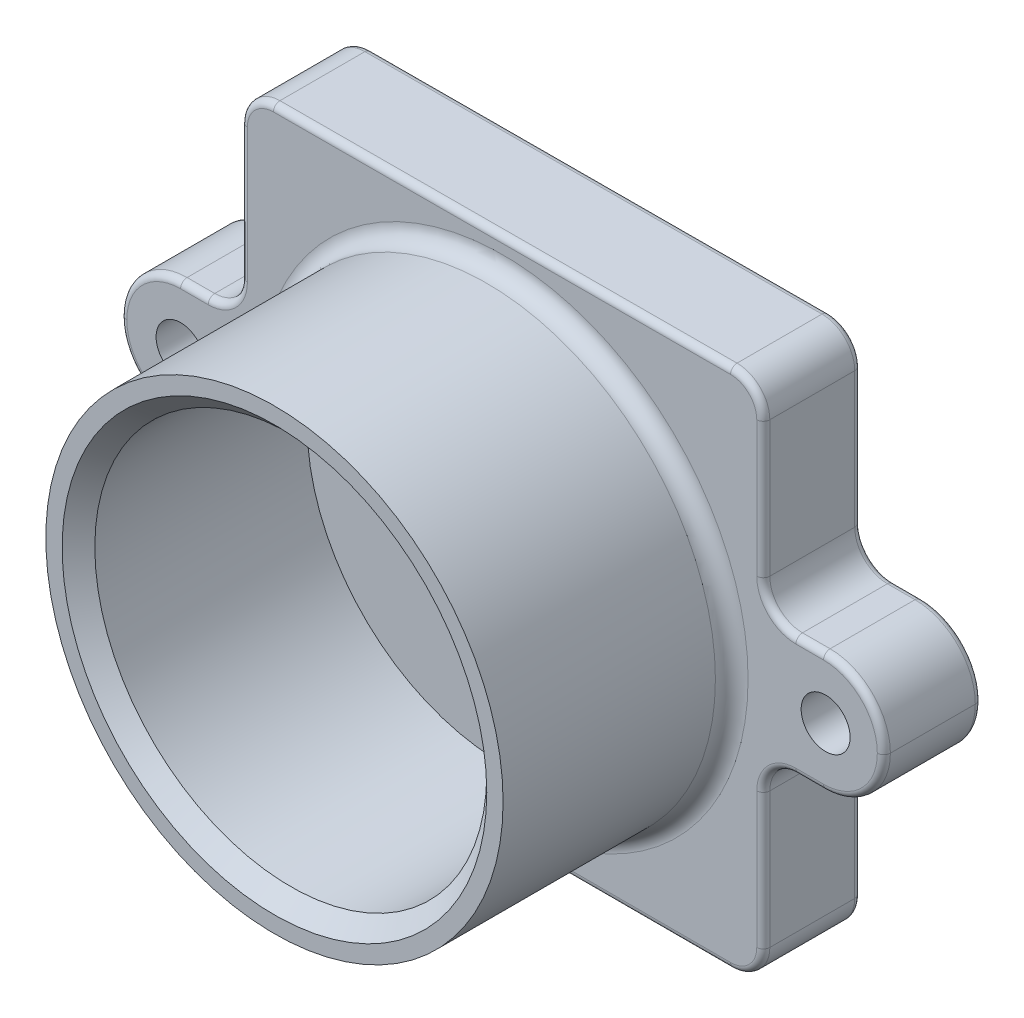
from build123d import *

# Parameters (mm, degrees)
BOSS_EXTRUDE1_DEPTH = 254
SKETCH2_OUTSIDE_W   = 748.341
SKETCH2_OUTSIDE_H   = 560.841
SKETCH2_OUTSIDE_R   = 177.8
CUT_EXTRUDE1_DEPTH  = 177.8
SKETCH3_R           = 152.4
CUT_EXTRUDE2_DEPTH  = 177.8
SKETCH4_R           = 19.05
CUT_EXTRUDE3_DEPTH  = 77.2
FILLET1_R           = 25.4
FILLET2_R           = 12.7
CHAMFER1_SIZE       = 12.7
FILLET3_R           = 5.08


with BuildPart() as part:
    # Sketch1 → Boss-Extrude1 (new body)
    with BuildSketch(Plane.XY):
        with BuildLine():
            Line((-203.92210878, 202.478230518), (202.328853722, 203.603457768))
            Line((202.328853722, 203.603457768), (202.328853722, 47.353145268))
            Line((202.328853722, 47.353145268), (249.203997472, 47.353145268))
            ThreePointArc((249.203997472, 47.353145268), (282.349757422, 33.623736467), (296.079166223, 0.477976517))
            ThreePointArc((296.079166223, 0.477976517), (282.349757422, -32.667783432), (249.203997472, -46.397192233))
            Line((249.203997472, -46.397192233), (202.328853722, -46.397192233))
            Line((202.328853722, -46.397192233), (202.328853722, -202.647504734))
            Line((202.328853722, -202.647504734), (-203.92210878, -202.647504734))
            Line((-203.92210878, -202.647504734), (-203.92210878, -46.397192233))
            Line((-203.92210878, -46.397192233), (-250.79725253, -46.397192233))
            ThreePointArc((-250.79725253, -46.397192233), (-283.94301248, -32.667783432), (-297.67242128, 0.477976517))
            ThreePointArc((-297.67242128, 0.477976517), (-283.94301248, 33.623736467), (-250.79725253, 47.353145268))
            Line((-250.79725253, 47.353145268), (-203.92210878, 47.353145268))
            Line((-203.92210878, 47.353145268), (-203.92210878, 202.478230518))
        make_face()
    extrude(amount=BOSS_EXTRUDE1_DEPTH)

    # Sketch2 outside → Cut-Extrude1 (cut)
    with BuildSketch(Plane.XY.offset(254)):
        with Locations((-0.7965, 0.4775)):
            Rectangle(SKETCH2_OUTSIDE_W, SKETCH2_OUTSIDE_H)
        Circle(SKETCH2_OUTSIDE_R, mode=Mode.SUBTRACT)
    extrude(amount=-CUT_EXTRUDE1_DEPTH, mode=Mode.SUBTRACT)

    # Sketch3 → Cut-Extrude2 (cut)
    with BuildSketch(Plane.XY.offset(254)):
        Circle(SKETCH3_R)
    extrude(amount=-CUT_EXTRUDE2_DEPTH, mode=Mode.SUBTRACT)

    # Sketch4 → Cut-Extrude3 (cut, through all)
    with BuildSketch(Plane.XY.offset(76.2)):
        with Locations((-250.797287549, 0.478011537)):
            Circle(SKETCH4_R)
        with Locations((250.797287549, 0.478011537)):
            Circle(SKETCH4_R)
    extrude(amount=-CUT_EXTRUDE3_DEPTH, mode=Mode.SUBTRACT)

    # Fillet1
    fillet1_edges = [part.edges().sort_by_distance(p)[0] for p in [
        (-203.92210878, 202.478230518, 38.1),
        (202.328853722, 203.603457768, 38.1),
        (202.328853722, 47.353145268, 38.1),
        (202.328853722, -46.397192233, 38.1),
        (202.328853722, -202.647504734, 38.1),
        (-203.92210878, -202.647504734, 38.1),
        (-203.92210878, -46.397192233, 38.1),
        (-203.92210878, 47.353145268, 38.1),
    ]]
    fillet(fillet1_edges, radius=FILLET1_R)

    # Fillet2
    fillet2_edges = [part.edges().sort_by_distance(p)[0] for p in [
        (-177.8, 0, 76.2),
    ]]
    fillet(fillet2_edges, radius=FILLET2_R)

    # Chamfer1
    chamfer1_edges = [part.edges().sort_by_distance(p)[0] for p in [
        (-152.4, 0, 254),
    ]]
    chamfer(chamfer1_edges, length=CHAMFER1_SIZE)

    # Fillet3
    fillet3_edges = [part.edges().sort_by_distance(p)[0] for p in [
        (-240.059680655, 47.353145268, 76.2),
        (202.328853722, -124.522348483, 76.2),
        (238.466425597, -46.397192233, 76.2),
        (202.328853722, 125.443076551, 76.2),
        (-0.866979762, 203.040649283, 76.2),
        (-196.507477093, 195.084107315, 76.2),
        (194.864475446, 196.118376148, 76.2),
        (194.889365964, -195.208016976, 76.2),
        (-196.482621022, -195.208016976, 76.2),
        (-211.361596538, -53.836679991, 0),
        (-211.361596538, -53.836679991, 76.2),
        (209.76834148, -53.836679991, 0),
        (209.76834148, -53.836679991, 76.2),
        (209.76834148, 54.792633025, 0),
        (209.76834148, 54.792633025, 76.2),
        (-211.361596538, 54.792633025, 0),
        (-211.361596538, 54.792633025, 76.2),
        (238.466425597, 47.353145268, 0),
        (282.349757422, 33.623736467, 0),
        (282.349757422, -32.667783432, 0),
        (-240.059680655, -46.397192233, 0),
        (-283.94301248, -32.667783432, 0),
        (-283.94301248, 33.623736467, 0),
        (-283.94301248, 33.623736467, 76.2),
        (-283.94301248, -32.667783432, 76.2),
        (-240.059680655, -46.397192233, 76.2),
        (282.349757422, -32.667783432, 76.2),
        (282.349757422, 33.623736467, 76.2),
        (238.466425597, 47.353145268, 76.2),
        (-0.796627529, -202.647504734, 76.2),
        (-0.796627529, -202.647504734, 0),
        (-203.92210878, 124.950815429, 0),
        (-0.866979762, 203.040649283, 0),
        (202.328853722, 125.443076551, 0),
        (238.466425597, -46.397192233, 0),
        (202.328853722, -124.522348483, 0),
        (-203.92210878, -124.522348483, 0),
        (-240.059680655, 47.353145268, 0),
        (-196.507477093, 195.084107315, 0),
        (194.864475446, 196.118376148, 0),
        (194.889365964, -195.208016976, 0),
        (-196.482621022, -195.208016976, 0),
        (-203.92210878, -124.522348483, 76.2),
        (-203.92210878, 124.950815429, 76.2),
    ]]
    fillet(fillet3_edges, radius=FILLET3_R)


solid = part.part
